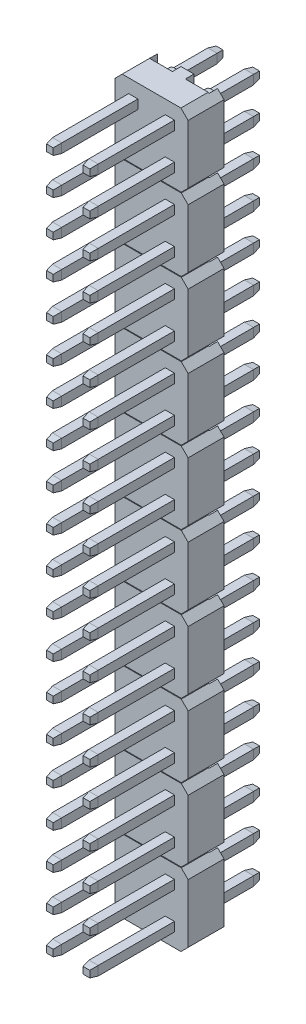
from build123d import *

# Parameters (mm, degrees)
SKETCH1_W                  = 0.64
SKETCH1_H                  = 0.64
BOSS_EXTRUDE1_DEPTH        = 5.3
BOSS_EXTRUDE1_2_DEPTH      = 5.3
BOSS_EXTRUDE1_3_DEPTH      = 5.3
BOSS_EXTRUDE1_4_DEPTH      = 5.3
SKETCH2_W                  = 0.64
SKETCH2_H                  = 0.64
BOSS_EXTRUDE2_DEPTH        = 0.5
BOSS_EXTRUDE2_TAPER        = 10
BOSS_EXTRUDE3_DEPTH        = 2.5
SKETCH5_W                  = 1.64
SKETCH5_H                  = 5.08
CUT_EXTRUDE1_DEPTH         = 0.6
SKETCH8_W                  = 0.64
SKETCH8_H                  = 0.64
BOSS_EXTRUDE4_DEPTH        = 3.6
BOSS_EXTRUDE4_2_DEPTH      = 3.6
BOSS_EXTRUDE4_3_DEPTH      = 3.6
BOSS_EXTRUDE4_4_DEPTH      = 3.6
SKETCH9_W                  = 0.64
SKETCH9_H                  = 0.64
BOSS_EXTRUDE5_DEPTH        = 0.5
BOSS_EXTRUDE5_TAPER        = 10
SKETCH10_R                 = 0.56
BOSS_EXTRUDE6_DEPTH        = 1
BOSS_EXTRUDE6_2_DEPTH      = 1
SZYK_LINIOWY1_COUNT        = 10
SZYK_LINIOWY1_PITCH        = 5.08
SZKIC1_W                   = 4.68427739
SZKIC1_H                   = 0.05
WYTNIJ_WYCI_GNI_CIE1_DEPTH = 7.0000001


with BuildPart() as part:
    # Sketch1 → Boss-Extrude1 (new body)
    with BuildSketch(Plane.XY):
        with Locations((-1.27, 1.27)):
            Rectangle(SKETCH1_W, SKETCH1_H)
    extrude(amount=BOSS_EXTRUDE1_DEPTH)



with BuildPart() as body_2:
    # Sketch1 → Boss-Extrude1 2 (new body)
    with BuildSketch(Plane.XY):
        with Locations((-1.27, -1.27)):
            Rectangle(SKETCH1_W, SKETCH1_H)
    extrude(amount=BOSS_EXTRUDE1_2_DEPTH)


with BuildPart() as body_3:
    # Sketch1 → Boss-Extrude1 3 (new body)
    with BuildSketch(Plane.XY):
        with Locations((1.27, 1.27)):
            Rectangle(SKETCH1_W, SKETCH1_H)
    extrude(amount=BOSS_EXTRUDE1_3_DEPTH)


with BuildPart() as body_4:
    # Sketch1 → Boss-Extrude1 4 (new body)
    with BuildSketch(Plane.XY):
        with Locations((1.27, -1.27)):
            Rectangle(SKETCH1_W, SKETCH1_H)
    extrude(amount=BOSS_EXTRUDE1_4_DEPTH)


with BuildPart() as part_1:
    add(part.part)

    add(body_2.part)  # Boss-Extrude2 merges body 2

    add(body_3.part)  # Boss-Extrude2 merges body 3

    add(body_4.part)  # Boss-Extrude2 merges body 4
    # Sketch2 → Boss-Extrude2 (add)
    with BuildSketch(Plane.XY.offset(5.3)):
        with Locations((-1.27, -1.27)):
            Rectangle(SKETCH2_W, SKETCH2_H)
        with Locations((-1.27, 1.27)):
            Rectangle(SKETCH2_W, SKETCH2_H)
        with Locations((1.27, -1.27)):
            Rectangle(SKETCH2_W, SKETCH2_H)
        with Locations((1.27, 1.27)):
            Rectangle(SKETCH2_W, SKETCH2_H)
    extrude(amount=BOSS_EXTRUDE2_DEPTH, taper=BOSS_EXTRUDE2_TAPER)


with BuildPart() as body_2_2:
    # Sketch3 → Boss-Extrude3 (new body)
    with BuildSketch(Plane.XY):
        Polygon((-2.04, 2.54), (2.04, 2.54), (2.54, 2.04), (2.54, -2.04), (2.04, -2.54), (-2.04, -2.54), (-2.54, -2.04), (-2.54, 2.04), align=None)
    extrude(amount=-BOSS_EXTRUDE3_DEPTH)

    # Sketch5 → Cut-Extrude1 (cut)
    with BuildSketch(Plane(origin=(0, 0, -2.5), x_dir=(-1, 0, 0), z_dir=(0, 0, -1))):
        with Locations((-1.27, 0)):
            Rectangle(SKETCH5_W, SKETCH5_H)
        with Locations((1.27, 0)):
            Rectangle(SKETCH5_W, SKETCH5_H)
    extrude(amount=-CUT_EXTRUDE1_DEPTH, mode=Mode.SUBTRACT)


with BuildPart() as body_3_2:
    # Sketch8 → Boss-Extrude4 (new body)
    with BuildSketch(Plane(origin=(0, 0, -1.9), x_dir=(-1, 0, 0), z_dir=(0, 0, -1))):
        with Locations((1.27, -1.27)):
            Rectangle(SKETCH8_W, SKETCH8_H)
    extrude(amount=BOSS_EXTRUDE4_DEPTH)



with BuildPart() as body_4_2:
    # Sketch8 → Boss-Extrude4 2 (new body)
    with BuildSketch(Plane(origin=(0, 0, -1.9), x_dir=(-1, 0, 0), z_dir=(0, 0, -1))):
        with Locations((1.27, 1.27)):
            Rectangle(SKETCH8_W, SKETCH8_H)
    extrude(amount=BOSS_EXTRUDE4_2_DEPTH)


with BuildPart() as body_5:
    # Sketch8 → Boss-Extrude4 3 (new body)
    with BuildSketch(Plane(origin=(0, 0, -1.9), x_dir=(-1, 0, 0), z_dir=(0, 0, -1))):
        with Locations((-1.27, 1.27)):
            Rectangle(SKETCH8_W, SKETCH8_H)
    extrude(amount=BOSS_EXTRUDE4_3_DEPTH)


with BuildPart() as body_6:
    # Sketch8 → Boss-Extrude4 4 (new body)
    with BuildSketch(Plane(origin=(0, 0, -1.9), x_dir=(-1, 0, 0), z_dir=(0, 0, -1))):
        with Locations((-1.27, -1.27)):
            Rectangle(SKETCH8_W, SKETCH8_H)
    extrude(amount=BOSS_EXTRUDE4_4_DEPTH)


with BuildPart() as body_3_2_1:
    add(body_3_2.part)

    add(body_4_2.part)  # Boss-Extrude5 merges body 4 2

    add(body_5.part)  # Boss-Extrude5 merges body 5

    add(body_6.part)  # Boss-Extrude5 merges body 6
    # Sketch9 → Boss-Extrude5 (add)
    with BuildSketch(Plane(origin=(0, 0, -5.5), x_dir=(-1, 0, 0), z_dir=(0, 0, -1))):
        with Locations((1.27, 1.27)):
            Rectangle(SKETCH9_W, SKETCH9_H)
        with Locations((1.27, -1.27)):
            Rectangle(SKETCH9_W, SKETCH9_H)
        with Locations((-1.27, -1.27)):
            Rectangle(SKETCH9_W, SKETCH9_H)
        with Locations((-1.27, 1.27)):
            Rectangle(SKETCH9_W, SKETCH9_H)
    extrude(amount=BOSS_EXTRUDE5_DEPTH, taper=BOSS_EXTRUDE5_TAPER)


with BuildPart() as body_4_3:
    # Sketch10 → Boss-Extrude6 (new body)
    with BuildSketch(Plane(origin=(0, 0, -1.9), x_dir=(-1, 0, 0), z_dir=(0, 0, -1))):
        with Locations((-1.27, 1.27)):
            Circle(SKETCH10_R)
    extrude(amount=BOSS_EXTRUDE6_DEPTH)


with BuildPart() as body_5_2:
    # Sketch10 → Boss-Extrude6 2 (new body)
    with BuildSketch(Plane(origin=(0, 0, -1.9), x_dir=(-1, 0, 0), z_dir=(0, 0, -1))):
        with Locations((1.27, 1.27)):
            Circle(SKETCH10_R)
    extrude(amount=BOSS_EXTRUDE6_2_DEPTH)


with BuildPart() as szyk_liniowy1_1:
    # Szyk liniowy1: pattern copy
    add(body_2_2.part.moved(Location(Vector(0, -1, 0) * (1 * SZYK_LINIOWY1_PITCH))))


with BuildPart() as szyk_liniowy1_2:
    # Szyk liniowy1: pattern copy
    add(body_2_2.part.moved(Location(Vector(0, -1, 0) * (2 * SZYK_LINIOWY1_PITCH))))


with BuildPart() as szyk_liniowy1_3:
    # Szyk liniowy1: pattern copy
    add(body_2_2.part.moved(Location(Vector(0, -1, 0) * (3 * SZYK_LINIOWY1_PITCH))))


with BuildPart() as szyk_liniowy1_4:
    # Szyk liniowy1: pattern copy
    add(body_2_2.part.moved(Location(Vector(0, -1, 0) * (4 * SZYK_LINIOWY1_PITCH))))


with BuildPart() as szyk_liniowy1_5:
    # Szyk liniowy1: pattern copy
    add(body_2_2.part.moved(Location(Vector(0, -1, 0) * (5 * SZYK_LINIOWY1_PITCH))))


with BuildPart() as szyk_liniowy1_6:
    # Szyk liniowy1: pattern copy
    add(body_2_2.part.moved(Location(Vector(0, -1, 0) * (6 * SZYK_LINIOWY1_PITCH))))


with BuildPart() as szyk_liniowy1_7:
    # Szyk liniowy1: pattern copy
    add(body_2_2.part.moved(Location(Vector(0, -1, 0) * (7 * SZYK_LINIOWY1_PITCH))))


with BuildPart() as szyk_liniowy1_8:
    # Szyk liniowy1: pattern copy
    add(body_2_2.part.moved(Location(Vector(0, -1, 0) * (8 * SZYK_LINIOWY1_PITCH))))


with BuildPart() as szyk_liniowy1_9:
    # Szyk liniowy1: pattern copy
    add(body_2_2.part.moved(Location(Vector(0, -1, 0) * (9 * SZYK_LINIOWY1_PITCH))))


with BuildPart() as szyk_liniowy1_10:
    # Szyk liniowy1: pattern copy
    add(part_1.part.moved(Location(Vector(0, -1, 0) * (1 * SZYK_LINIOWY1_PITCH))))


with BuildPart() as szyk_liniowy1_11:
    # Szyk liniowy1: pattern copy
    add(part_1.part.moved(Location(Vector(0, -1, 0) * (2 * SZYK_LINIOWY1_PITCH))))


with BuildPart() as szyk_liniowy1_12:
    # Szyk liniowy1: pattern copy
    add(part_1.part.moved(Location(Vector(0, -1, 0) * (3 * SZYK_LINIOWY1_PITCH))))


with BuildPart() as szyk_liniowy1_13:
    # Szyk liniowy1: pattern copy
    add(part_1.part.moved(Location(Vector(0, -1, 0) * (4 * SZYK_LINIOWY1_PITCH))))


with BuildPart() as szyk_liniowy1_14:
    # Szyk liniowy1: pattern copy
    add(part_1.part.moved(Location(Vector(0, -1, 0) * (5 * SZYK_LINIOWY1_PITCH))))


with BuildPart() as szyk_liniowy1_15:
    # Szyk liniowy1: pattern copy
    add(part_1.part.moved(Location(Vector(0, -1, 0) * (6 * SZYK_LINIOWY1_PITCH))))


with BuildPart() as szyk_liniowy1_16:
    # Szyk liniowy1: pattern copy
    add(part_1.part.moved(Location(Vector(0, -1, 0) * (7 * SZYK_LINIOWY1_PITCH))))


with BuildPart() as szyk_liniowy1_17:
    # Szyk liniowy1: pattern copy
    add(part_1.part.moved(Location(Vector(0, -1, 0) * (8 * SZYK_LINIOWY1_PITCH))))


with BuildPart() as szyk_liniowy1_18:
    # Szyk liniowy1: pattern copy
    add(part_1.part.moved(Location(Vector(0, -1, 0) * (9 * SZYK_LINIOWY1_PITCH))))


with BuildPart() as szyk_liniowy1_19:
    # Szyk liniowy1: pattern copy
    add(body_3_2_1.part.moved(Location(Vector(0, -1, 0) * (1 * SZYK_LINIOWY1_PITCH))))


with BuildPart() as szyk_liniowy1_20:
    # Szyk liniowy1: pattern copy
    add(body_3_2_1.part.moved(Location(Vector(0, -1, 0) * (2 * SZYK_LINIOWY1_PITCH))))


with BuildPart() as szyk_liniowy1_21:
    # Szyk liniowy1: pattern copy
    add(body_3_2_1.part.moved(Location(Vector(0, -1, 0) * (3 * SZYK_LINIOWY1_PITCH))))


with BuildPart() as szyk_liniowy1_22:
    # Szyk liniowy1: pattern copy
    add(body_3_2_1.part.moved(Location(Vector(0, -1, 0) * (4 * SZYK_LINIOWY1_PITCH))))


with BuildPart() as szyk_liniowy1_23:
    # Szyk liniowy1: pattern copy
    add(body_3_2_1.part.moved(Location(Vector(0, -1, 0) * (5 * SZYK_LINIOWY1_PITCH))))


with BuildPart() as szyk_liniowy1_24:
    # Szyk liniowy1: pattern copy
    add(body_3_2_1.part.moved(Location(Vector(0, -1, 0) * (6 * SZYK_LINIOWY1_PITCH))))


with BuildPart() as szyk_liniowy1_25:
    # Szyk liniowy1: pattern copy
    add(body_3_2_1.part.moved(Location(Vector(0, -1, 0) * (7 * SZYK_LINIOWY1_PITCH))))


with BuildPart() as szyk_liniowy1_26:
    # Szyk liniowy1: pattern copy
    add(body_3_2_1.part.moved(Location(Vector(0, -1, 0) * (8 * SZYK_LINIOWY1_PITCH))))


with BuildPart() as szyk_liniowy1_27:
    # Szyk liniowy1: pattern copy
    add(body_3_2_1.part.moved(Location(Vector(0, -1, 0) * (9 * SZYK_LINIOWY1_PITCH))))


with BuildPart() as wytnij_wyci_gni_cie1_tool:
    # Szkic1 → Wytnij-wyciągnięcie1 (new body, through all)
    with BuildSketch(Plane.XY):
        with Locations((0, -7.62)):
            Rectangle(SZKIC1_W, SZKIC1_H)
        with Locations((0, -2.54)):
            Rectangle(SZKIC1_W, SZKIC1_H)
        with Locations((0, -12.7)):
            Rectangle(SZKIC1_W, SZKIC1_H)
        with Locations((0, -17.78)):
            Rectangle(SZKIC1_W, SZKIC1_H)
        with Locations((0, -22.86)):
            Rectangle(SZKIC1_W, SZKIC1_H)
        with Locations((0, -27.94)):
            Rectangle(SZKIC1_W, SZKIC1_H)
        with Locations((0, -33.02)):
            Rectangle(SZKIC1_W, SZKIC1_H)
        with Locations((0, -38.1)):
            Rectangle(SZKIC1_W, SZKIC1_H)
        with Locations((0, -43.18)):
            Rectangle(SZKIC1_W, SZKIC1_H)
    extrude(amount=-WYTNIJ_WYCI_GNI_CIE1_DEPTH)


with BuildPart() as body_2_2_1:
    add(body_2_2.part)

    # Wytnij-wyciągnięcie1: cut by wytnij_wyci_gni_cie1_tool
    add(wytnij_wyci_gni_cie1_tool.part, mode=Mode.SUBTRACT)


with BuildPart() as szyk_liniowy1_1_1:
    add(szyk_liniowy1_1.part)

    # Wytnij-wyciągnięcie1: cut by wytnij_wyci_gni_cie1_tool
    add(wytnij_wyci_gni_cie1_tool.part, mode=Mode.SUBTRACT)


with BuildPart() as szyk_liniowy1_2_1:
    add(szyk_liniowy1_2.part)

    # Wytnij-wyciągnięcie1: cut by wytnij_wyci_gni_cie1_tool
    add(wytnij_wyci_gni_cie1_tool.part, mode=Mode.SUBTRACT)


with BuildPart() as szyk_liniowy1_3_1:
    add(szyk_liniowy1_3.part)

    # Wytnij-wyciągnięcie1: cut by wytnij_wyci_gni_cie1_tool
    add(wytnij_wyci_gni_cie1_tool.part, mode=Mode.SUBTRACT)


with BuildPart() as szyk_liniowy1_4_1:
    add(szyk_liniowy1_4.part)

    # Wytnij-wyciągnięcie1: cut by wytnij_wyci_gni_cie1_tool
    add(wytnij_wyci_gni_cie1_tool.part, mode=Mode.SUBTRACT)


with BuildPart() as szyk_liniowy1_5_1:
    add(szyk_liniowy1_5.part)

    # Wytnij-wyciągnięcie1: cut by wytnij_wyci_gni_cie1_tool
    add(wytnij_wyci_gni_cie1_tool.part, mode=Mode.SUBTRACT)


with BuildPart() as szyk_liniowy1_6_1:
    add(szyk_liniowy1_6.part)

    # Wytnij-wyciągnięcie1: cut by wytnij_wyci_gni_cie1_tool
    add(wytnij_wyci_gni_cie1_tool.part, mode=Mode.SUBTRACT)


with BuildPart() as szyk_liniowy1_7_1:
    add(szyk_liniowy1_7.part)

    # Wytnij-wyciągnięcie1: cut by wytnij_wyci_gni_cie1_tool
    add(wytnij_wyci_gni_cie1_tool.part, mode=Mode.SUBTRACT)


with BuildPart() as szyk_liniowy1_8_1:
    add(szyk_liniowy1_8.part)

    # Wytnij-wyciągnięcie1: cut by wytnij_wyci_gni_cie1_tool
    add(wytnij_wyci_gni_cie1_tool.part, mode=Mode.SUBTRACT)


with BuildPart() as szyk_liniowy1_9_1:
    add(szyk_liniowy1_9.part)

    # Wytnij-wyciągnięcie1: cut by wytnij_wyci_gni_cie1_tool
    add(wytnij_wyci_gni_cie1_tool.part, mode=Mode.SUBTRACT)


solid = Compound([part_1.part, body_3_2_1.part, body_4_3.part, body_5_2.part, szyk_liniowy1_10.part, szyk_liniowy1_11.part, szyk_liniowy1_12.part, szyk_liniowy1_13.part, szyk_liniowy1_14.part, szyk_liniowy1_15.part, szyk_liniowy1_16.part, szyk_liniowy1_17.part, szyk_liniowy1_18.part, szyk_liniowy1_19.part, szyk_liniowy1_20.part, szyk_liniowy1_21.part, szyk_liniowy1_22.part, szyk_liniowy1_23.part, szyk_liniowy1_24.part, szyk_liniowy1_25.part, szyk_liniowy1_26.part, szyk_liniowy1_27.part, body_2_2_1.part, szyk_liniowy1_1_1.part, szyk_liniowy1_2_1.part, szyk_liniowy1_3_1.part, szyk_liniowy1_4_1.part, szyk_liniowy1_5_1.part, szyk_liniowy1_6_1.part, szyk_liniowy1_7_1.part, szyk_liniowy1_8_1.part, szyk_liniowy1_9_1.part])
